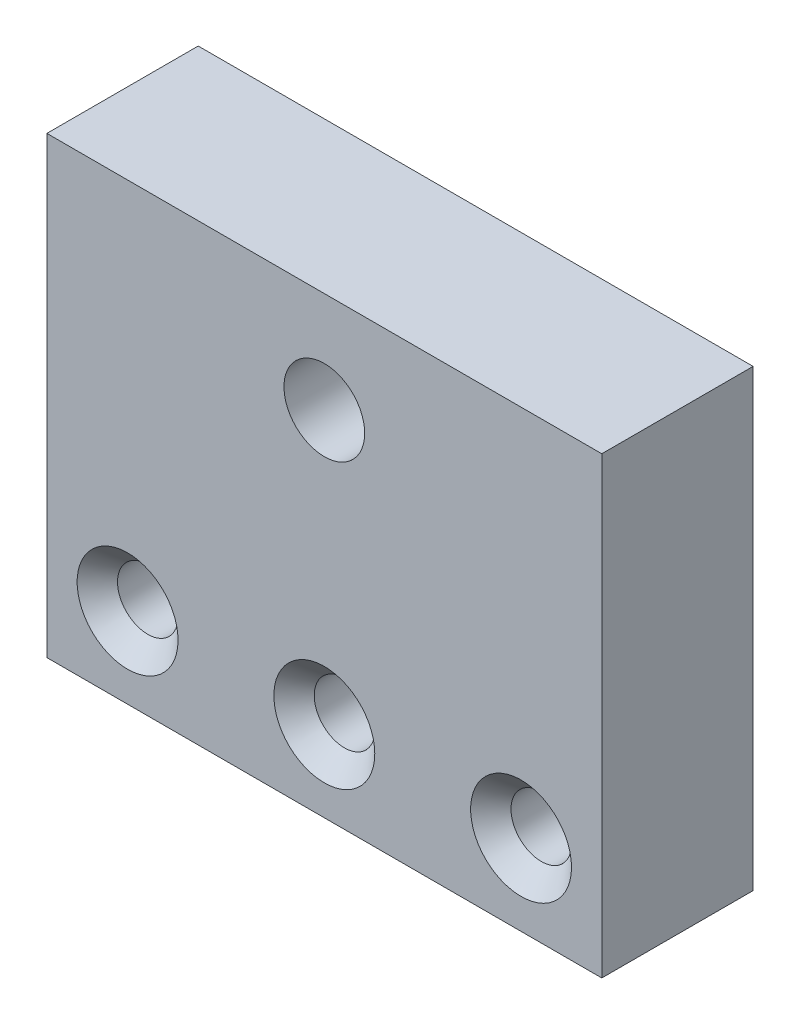
from build123d import *

# Parameters (mm, degrees)
SKETCH1_W                       = 55
SKETCH1_H                       = 45
BOSS_EXTRUDE1_DEPTH             = 7.5
F_6_0MM_DOWEL_HOLE1_D           = 6
F_6_0MM_DOWEL_HOLE1_CSINK_D     = 10
F_6_0MM_DOWEL_HOLE1_CSINK_ANGLE = 90
F_8_0MM_DOWEL_HOLE1_D           = 8


with BuildPart() as part:
    # Sketch1 → Boss-Extrude1 (new body, symmetric)
    with BuildSketch(Plane.XY):
        with Locations((27.5, 22.5)):
            Rectangle(SKETCH1_W, SKETCH1_H)
    extrude(amount=BOSS_EXTRUDE1_DEPTH, both=True)

    # Ø6.0mm Dowel Hole1 (through all)
    with Locations(Plane(origin=(8, 8, 7.5), x_dir=(1, 0, 0), z_dir=(0, 0, 1))):
        with Locations((0, 0), (19.5, 0), (39, 0)):
            CounterSinkHole(F_6_0MM_DOWEL_HOLE1_D / 2, F_6_0MM_DOWEL_HOLE1_CSINK_D / 2, counter_sink_angle=F_6_0MM_DOWEL_HOLE1_CSINK_ANGLE)

    # Ø8.0mm Dowel Hole1 (through all)
    with Locations(Plane(origin=(27.5, 35, 7.5), x_dir=(1, 0, 0), z_dir=(0, 0, 1))):
        with Locations((0, 0)):
            Hole(F_8_0MM_DOWEL_HOLE1_D / 2)


solid = part.part
